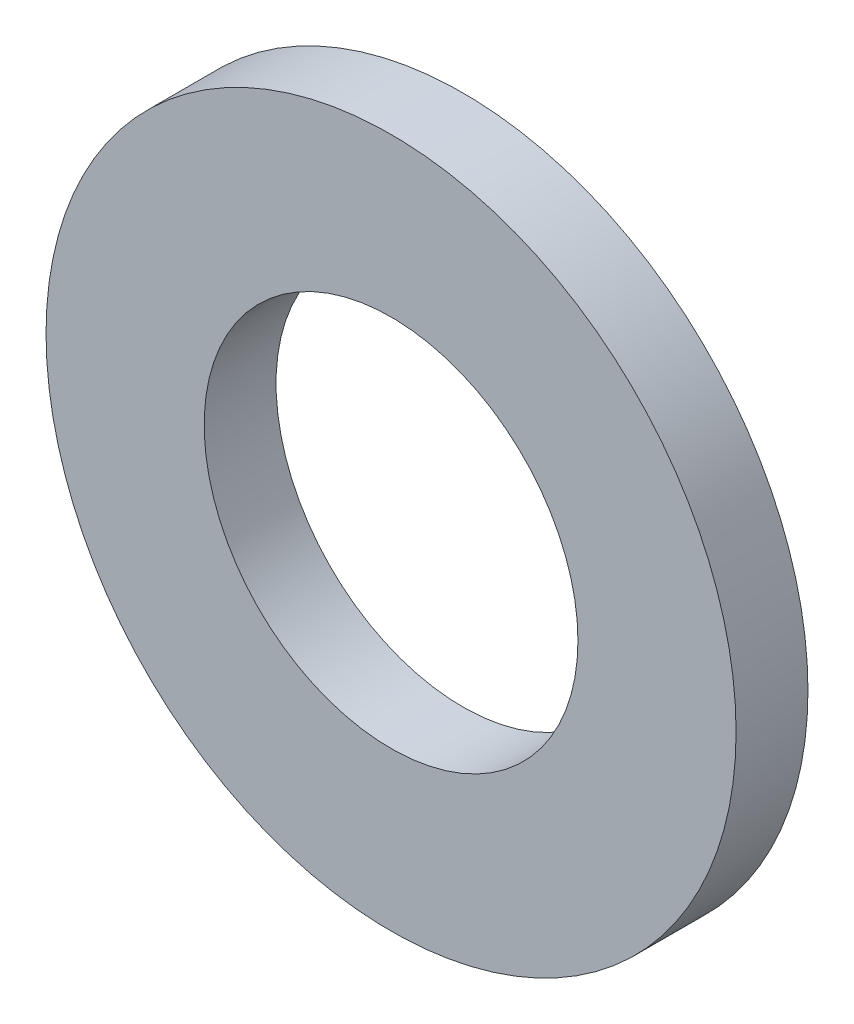
from build123d import *

# Parameters (mm, degrees)
SKETCH_1_R      = 12
SKETCH_1_R_2    = 6.5
EXTRUDE_1_DEPTH = 2.5


with BuildPart() as part:
    # Эскиз1 → Бобышка-Вытянуть1 (new body)
    with BuildSketch(Plane.XY):
        Circle(SKETCH_1_R)
        Circle(SKETCH_1_R_2, mode=Mode.SUBTRACT)
    extrude(amount=EXTRUDE_1_DEPTH)


solid = part.part
